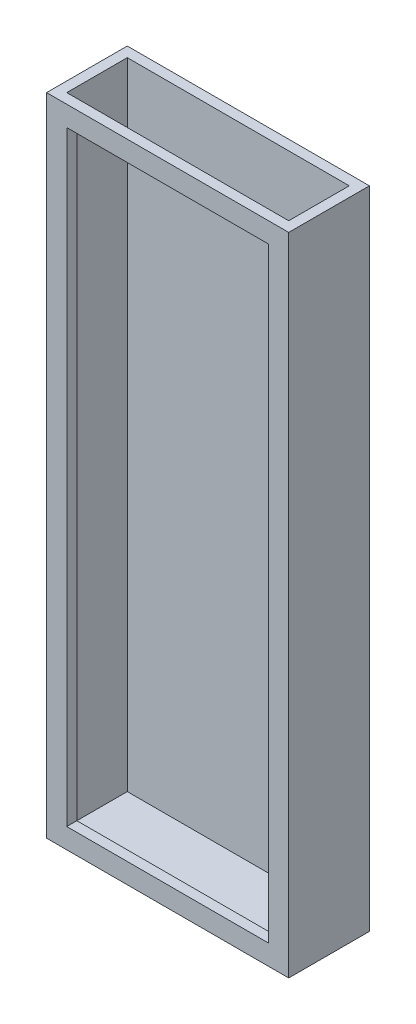
from build123d import *

# Parameters (mm, degrees)
SKETCH1_W           = 76.2
SKETCH1_H           = 25.4
BOSS_EXTRUDE5_DEPTH = 203.2
SKETCH4_W           = 69.85
SKETCH4_H           = 19.05
CUT_EXTRUDE1_DEPTH  = 200.025
SKETCH5_W           = 63.5
SKETCH5_H           = 190.5
CUT_EXTRUDE2_DEPTH  = 8.89


with BuildPart() as part:
    # Sketch1 → Boss-Extrude5 (new body)
    with BuildSketch(Plane(origin=(0, 0, 0), x_dir=(1, 0, 0), z_dir=(0, 1, 0))):
        Rectangle(SKETCH1_W, SKETCH1_H)
    extrude(amount=BOSS_EXTRUDE5_DEPTH)

    # Sketch4 → Cut-Extrude1 (cut)
    with BuildSketch(Plane(origin=(0, 203.2, 0), x_dir=(1, 0, 0), z_dir=(0, 1, 0))):
        Rectangle(SKETCH4_W, SKETCH4_H)
    extrude(amount=-CUT_EXTRUDE1_DEPTH, mode=Mode.SUBTRACT)

    # Sketch5 → Cut-Extrude2 (cut)
    with BuildSketch(Plane.XY.offset(12.7)):
        with Locations((0, 101.6)):
            Rectangle(SKETCH5_W, SKETCH5_H)
    extrude(amount=-CUT_EXTRUDE2_DEPTH, mode=Mode.SUBTRACT)


solid = part.part
